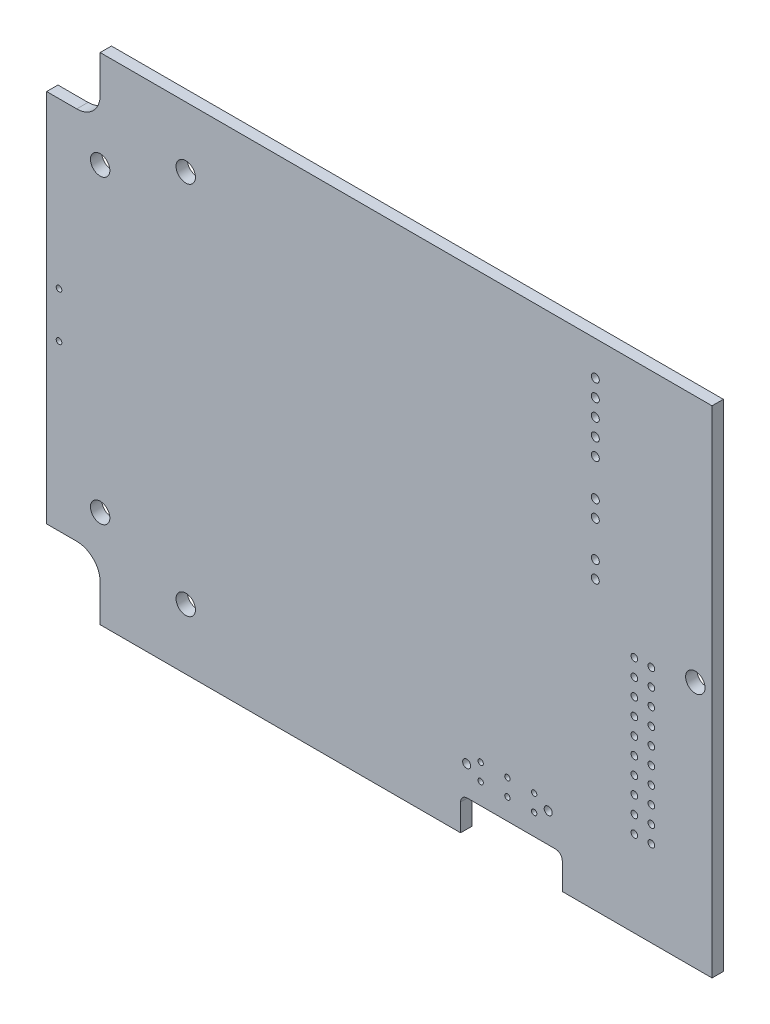
from build123d import *

# Parameters (mm, degrees)
BOSS_EXTRUDE1_DEPTH          = 1.68939972
F_2_9_2_9_DIAMETER_HOLE1_D   = 2.89999928
HOLE1_D                      = 1.1999976
LPATTERN1_COUNT              = 2
LPATTERN1_PITCH              = 2.540004919
HOLE2_D                      = 0.999998
LPATTERN2_COUNT              = 2
LPATTERN2_PITCH              = 2.54
LPATTERN2_COUNT_DIR2         = 10
LPATTERN2_PITCH_DIR2         = 2.54
HOLE3_D                      = 1.1999976
LPATTERN3_COUNT              = 5
LPATTERN3_PITCH              = 2.54
F_2_9_2_9_DIAMETER_HOLE2_D   = 2.89999928
HOLE4_D                      = 1.1999976
LPATTERN4_COUNT              = 2
LPATTERN4_PITCH              = 2.540004919
F_0_85_0_85_DIAMETER_HOLE1_D = 0.85000084
HOLE5_D                      = 0.7999984
LPATTERN5_COUNT              = 3
LPATTERN5_PITCH              = 3.99999962
LPATTERN5_COUNT_DIR2         = 2
LPATTERN5_PITCH_DIR2         = 2.50000008
F_2_9_2_9_DIAMETER_HOLE3_D   = 2.89999928
F_2_9_2_9_DIAMETER_HOLE4_D   = 2.89999928
F_0_85_0_85_DIAMETER_HOLE2_D = 0.85000084
HOLE6_D                      = 1.1999976
LPATTERN6_COUNT              = 2
LPATTERN6_PITCH              = 12.200001
F_2_9_2_9_DIAMETER_HOLE5_D   = 2.89999928


with BuildPart() as part:
    # Sketch1 → Boss-Extrude1 (new body)
    with BuildSketch(Plane.XY.offset(1.68939972)):
        with BuildLine():
            Line((87.300003052, 25.399999619), (87.300003052, 29.399999619))
            ThreePointArc((87.300003052, 29.399999619), (87.592896271, 30.1071064), (88.300003052, 30.399999619))
            Line((88.300003052, 30.399999619), (101.5, 30.399999619))
            ThreePointArc((101.5, 30.399999619), (102.207106781, 30.1071064), (102.5, 29.399999619))
            Line((102.5, 29.399999619), (102.5, 25.399999619))
            Line((102.5, 25.399999619), (124.900001526, 25.399999619))
            Line((124.900001526, 25.399999619), (124.900001526, 99.5))
            Line((124.900001526, 99.5), (33.400001526, 99.5))
            Line((33.400001526, 99.5), (33.400001526, 93.949998856))
            ThreePointArc((33.400001526, 93.949998856), (32.374874701, 91.475123773), (29.899999619, 90.449996948))
            Line((29.899999619, 90.449996948), (25.399999619, 90.449996948))
            Line((25.399999619, 90.449996948), (25.399999619, 34.450000763))
            Line((25.399999619, 34.450000763), (29.899999619, 34.450000763))
            ThreePointArc((29.899999619, 34.450000763), (32.374874701, 33.424873938), (33.400001526, 30.949998856))
            Line((33.400001526, 30.949998856), (33.400001526, 25.399999619))
            Line((33.400001526, 25.399999619), (87.300003052, 25.399999619))
        make_face()
    extrude(amount=-BOSS_EXTRUDE1_DEPTH)

    # Ø2.9 (2.9) Diameter Hole1 (through all)
    with Locations(Plane(origin=(0, 0, 0), x_dir=(-1, 0, 0), z_dir=(0, 0, -1))):
        with Locations((-122.39998888, 62.44998432)):
            Hole(F_2_9_2_9_DIAMETER_HOLE1_D / 2)

    # Hole1 (through all)
    with Locations(Plane(origin=(0, 0, 0), x_dir=(-1, 0, 0), z_dir=(0, 0, -1))):
        with Locations((-107.44449936, 78.74)):
            hole1 = Hole(HOLE1_D / 2)

    # LPattern1: Hole1 ×2
    with Locations(*[Vector(-0.0019679961889539077, -0.9999980634936251, 0) * (i * LPATTERN1_PITCH) for i in range(1, LPATTERN1_COUNT)]):
        add(hole1, mode=Mode.SUBTRACT)

    # Hole2 (through all)
    with Locations(Plane(origin=(0, 0, 0), x_dir=(-1, 0, 0), z_dir=(0, 0, -1))):
        with Locations((-113.284, 38.227)):
            hole2 = Hole(HOLE2_D / 2)

    # LPattern2: Hole2 2 × 10
    with Locations(*[(i * LPATTERN2_PITCH, j * LPATTERN2_PITCH_DIR2, 0) for i in range(LPATTERN2_COUNT) for j in range(LPATTERN2_COUNT_DIR2) if (i, j) != (0, 0)]):
        add(hole2, mode=Mode.SUBTRACT)

    # Hole3 (through all)
    with Locations(Plane(origin=(0, 0, 0), x_dir=(-1, 0, 0), z_dir=(0, 0, -1))):
        with Locations((-107.442, 94.361)):
            hole3 = Hole(HOLE3_D / 2)

    # LPattern3: Hole3 ×5
    with Locations(*[(0, -i * LPATTERN3_PITCH, 0) for i in range(1, LPATTERN3_COUNT)]):
        add(hole3, mode=Mode.SUBTRACT)

    # Ø2.9 (2.9) Diameter Hole2 (through all)
    with Locations(Plane(origin=(0, 0, 0), x_dir=(-1, 0, 0), z_dir=(0, 0, -1))):
        with Locations((-33.399984, 84.94998504)):
            Hole(F_2_9_2_9_DIAMETER_HOLE2_D / 2)

    # Hole4 (through all)
    with Locations(Plane(origin=(0, 0, 0), x_dir=(-1, 0, 0), z_dir=(0, 0, -1))):
        with Locations((-107.43950064, 68.326)):
            hole4 = Hole(HOLE4_D / 2)

    # LPattern4: Hole4 ×2
    with Locations(*[Vector(0.001967996188953908, 0.9999980634936252, 0) * (i * LPATTERN4_PITCH) for i in range(1, LPATTERN4_COUNT)]):
        add(hole4, mode=Mode.SUBTRACT)

    # Ø0.85 (0.85) Diameter Hole1 (through all)
    with Locations(Plane(origin=(0, 0, 0), x_dir=(-1, 0, 0), z_dir=(0, 0, -1))):
        with Locations((-27.25008266, 65.84998768)):
            Hole(F_0_85_0_85_DIAMETER_HOLE1_D / 2)

    # Hole5 (through all)
    with Locations(Plane(origin=(0, 0, 0), x_dir=(-1, 0, 0), z_dir=(0, 0, -1))):
        with Locations((-90.29998196, 36.04998632)):
            hole5 = Hole(HOLE5_D / 2)

    # LPattern5: Hole5 3 × 2
    with Locations(*[(i * LPATTERN5_PITCH, -j * LPATTERN5_PITCH_DIR2, 0) for i in range(LPATTERN5_COUNT) for j in range(LPATTERN5_COUNT_DIR2) if (i, j) != (0, 0)]):
        add(hole5, mode=Mode.SUBTRACT)

    # Ø2.9 (2.9) Diameter Hole3 (through all)
    with Locations(Plane(origin=(0, 0, 0), x_dir=(-1, 0, 0), z_dir=(0, 0, -1))):
        with Locations((-33.399984, 39.9499836)):
            Hole(F_2_9_2_9_DIAMETER_HOLE3_D / 2)

    # Ø2.9 (2.9) Diameter Hole4 (through all)
    with Locations(Plane(origin=(0, 0, 0), x_dir=(-1, 0, 0), z_dir=(0, 0, -1))):
        with Locations((-46.1999838, 34.44998952)):
            Hole(F_2_9_2_9_DIAMETER_HOLE4_D / 2)

    # Ø0.85 (0.85) Diameter Hole2 (through all)
    with Locations(Plane(origin=(0, 0, 0), x_dir=(-1, 0, 0), z_dir=(0, 0, -1))):
        with Locations((-27.25008266, 59.04998604)):
            Hole(F_0_85_0_85_DIAMETER_HOLE2_D / 2)

    # Hole6 (through all)
    with Locations(Plane(origin=(0, 0, 0), x_dir=(-1, 0, 0), z_dir=(0, 0, -1))):
        with Locations((-88.19998108, 34.79998628)):
            hole6 = Hole(HOLE6_D / 2)

    # LPattern6: Hole6 ×2
    with Locations(*[(i * LPATTERN6_PITCH, 0, 0) for i in range(1, LPATTERN6_COUNT)]):
        add(hole6, mode=Mode.SUBTRACT)

    # Ø2.9 (2.9) Diameter Hole5 (through all)
    with Locations(Plane(origin=(0, 0, 0), x_dir=(-1, 0, 0), z_dir=(0, 0, -1))):
        with Locations((-46.1999838, 90.44998928)):
            Hole(F_2_9_2_9_DIAMETER_HOLE5_D / 2)


solid = part.part
